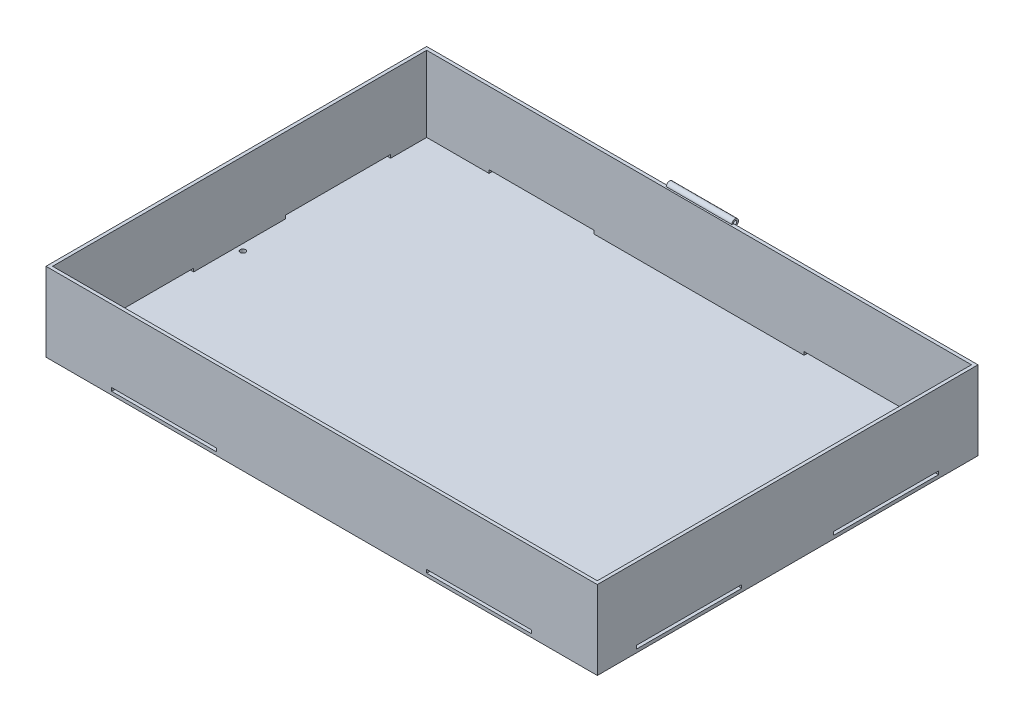
from build123d import *

# Parameters (mm, degrees)
SKETCH1_W           = 1066.8
SKETCH1_H           = 736.6
BOSS_EXTRUDE1_DEPTH = 152.4
SHELL1_T            = -6.35
SKETCH2_R           = 5.08
CUT_EXTRUDE1_DEPTH  = 7.35
SKETCH3_W           = 203.2
SKETCH3_H           = 6.35
CUT_EXTRUDE3_DEPTH  = 737.6
SKETCH4_W           = 203.2
SKETCH4_H           = 6.35
CUT_EXTRUDE4_DEPTH  = 1067.8
SKETCH6_R           = 3.175
BOSS_EXTRUDE3_DEPTH = 63.5


with BuildPart() as part:
    # Sketch1 → Boss-Extrude1 (new body)
    with BuildSketch(Plane(origin=(0, 0, 0), x_dir=(1, 0, 0), z_dir=(0, 1, 0))):
        Rectangle(SKETCH1_W, SKETCH1_H)
    extrude(amount=BOSS_EXTRUDE1_DEPTH)

    # Shell1
    shell1_openings = [part.faces().sort_by_distance(p)[0] for p in [
        (0, 152.4, 0),
    ]]
    offset(amount=SHELL1_T, openings=shell1_openings, kind=Kind.INTERSECTION)

    # Sketch2 → Cut-Extrude1 (cut, through all)
    with BuildSketch(Plane(origin=(0, 6.35, 0), x_dir=(1, 0, 0), z_dir=(0, 1, 0))):
        with Locations((-514.35, -6.35)):
            Circle(SKETCH2_R)
        with Locations((514.35, -6.35)):
            Circle(SKETCH2_R)
    extrude(amount=-CUT_EXTRUDE1_DEPTH, mode=Mode.SUBTRACT)

    # Sketch3 → Cut-Extrude3 (cut, through all)
    with BuildSketch(Plane.XY.offset(368.3)):
        with Locations((-304.8, 9.525)):
            Rectangle(SKETCH3_W, SKETCH3_H)
        with Locations((304.8, 9.525)):
            Rectangle(SKETCH3_W, SKETCH3_H)
    extrude(amount=-CUT_EXTRUDE3_DEPTH, mode=Mode.SUBTRACT)

    # Sketch4 → Cut-Extrude4 (cut, through all)
    with BuildSketch(Plane.ZY.offset(533.4)):
        with Locations((-190.5, 9.525)):
            Rectangle(SKETCH4_W, SKETCH4_H)
        with Locations((190.5, 9.525)):
            Rectangle(SKETCH4_W, SKETCH4_H)
    extrude(amount=-CUT_EXTRUDE4_DEPTH, mode=Mode.SUBTRACT)

    # Sketch6 → Boss-Extrude3 (add, symmetric)
    with BuildSketch(Plane.ZY.offset(3.175)):
        with BuildLine():
            ThreePointArc((-365.06301296, 152.4), (-371.475, 158.81198704), (-377.88698704, 152.4))
            ThreePointArc((-377.88698704, 152.4), (-371.475, 145.98801296), (-365.06301296, 152.4))
        make_face()
        with Locations((-371.475, 152.4)):
            Circle(SKETCH6_R, mode=Mode.SUBTRACT)
    extrude(amount=BOSS_EXTRUDE3_DEPTH, both=True)


solid = part.part
